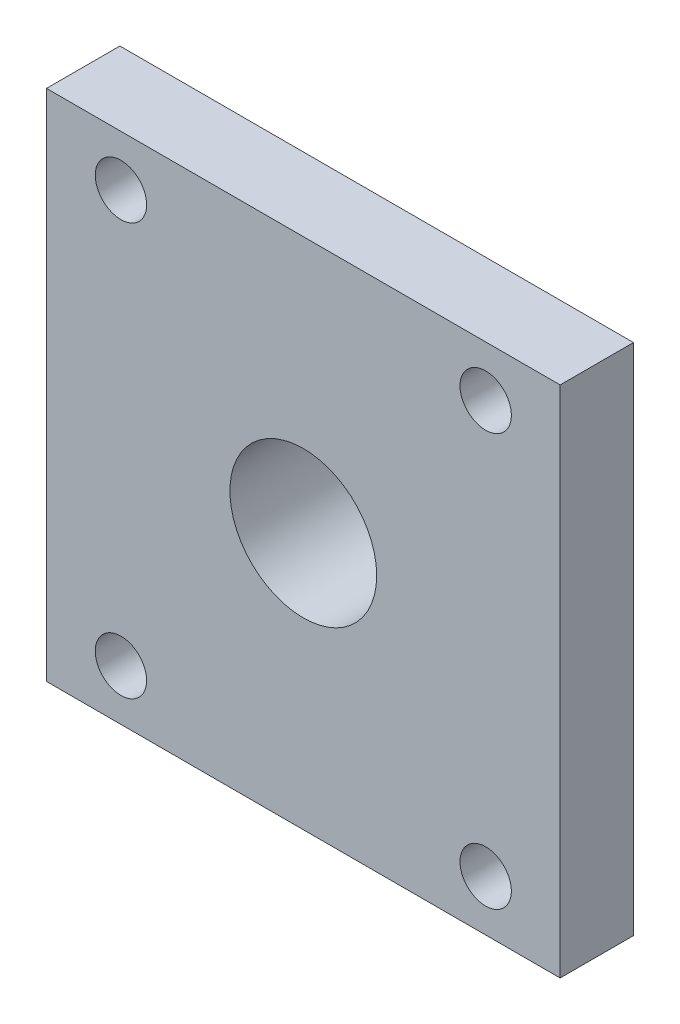
from build123d import *

# Parameters (mm, degrees)
SKETCH1_W           = 70
SKETCH1_H           = 70
BOSS_EXTRUDE1_DEPTH = 10
SKETCH2_R           = 10
CUT_EXTRUDE1_DEPTH  = 10
SKETCH4_R           = 3.5
CUT_EXTRUDE2_DEPTH  = 35
SKETCH5_R           = 13.071961786
SKETCH5_R_2         = 10
BOSS_EXTRUDE3_DEPTH = 15


with BuildPart() as part:
    # Sketch1 → Boss-Extrude1 (new body)
    with BuildSketch(Plane.XY):
        Rectangle(SKETCH1_W, SKETCH1_H)
    extrude(amount=BOSS_EXTRUDE1_DEPTH)

    # Sketch2 → Cut-Extrude1 (cut)
    with BuildSketch(Plane.XY.offset(10)):
        Circle(SKETCH2_R)
    extrude(amount=-CUT_EXTRUDE1_DEPTH, mode=Mode.SUBTRACT)

    # Sketch4 → Cut-Extrude2 (cut)
    with BuildSketch(Plane(origin=(0, 0, 0), x_dir=(-1, 0, 0), z_dir=(0, 0, -1))):
        with Locations((-24.855592085, 28.07934369)):
            Circle(SKETCH4_R)
        with Locations((24.855592085, 28.07934369)):
            Circle(SKETCH4_R)
        with Locations((24.855592085, -28.07934369)):
            Circle(SKETCH4_R)
        with Locations((-24.855592085, -28.07934369)):
            Circle(SKETCH4_R)
    extrude(amount=-CUT_EXTRUDE2_DEPTH, mode=Mode.SUBTRACT)

    # Sketch5 → Boss-Extrude3 (add)
    with BuildSketch(Plane(origin=(0, 0, 0), x_dir=(-1, 0, 0), z_dir=(0, 0, -1))):
        with Locations(Location((0, 0, 0), (0, 0, 180))):
            Circle(SKETCH5_R)
        with Locations(Location((0, 0, 0), (0, 0, 180))):
            Circle(SKETCH5_R_2, mode=Mode.SUBTRACT)
    extrude(amount=BOSS_EXTRUDE3_DEPTH)


solid = part.part
